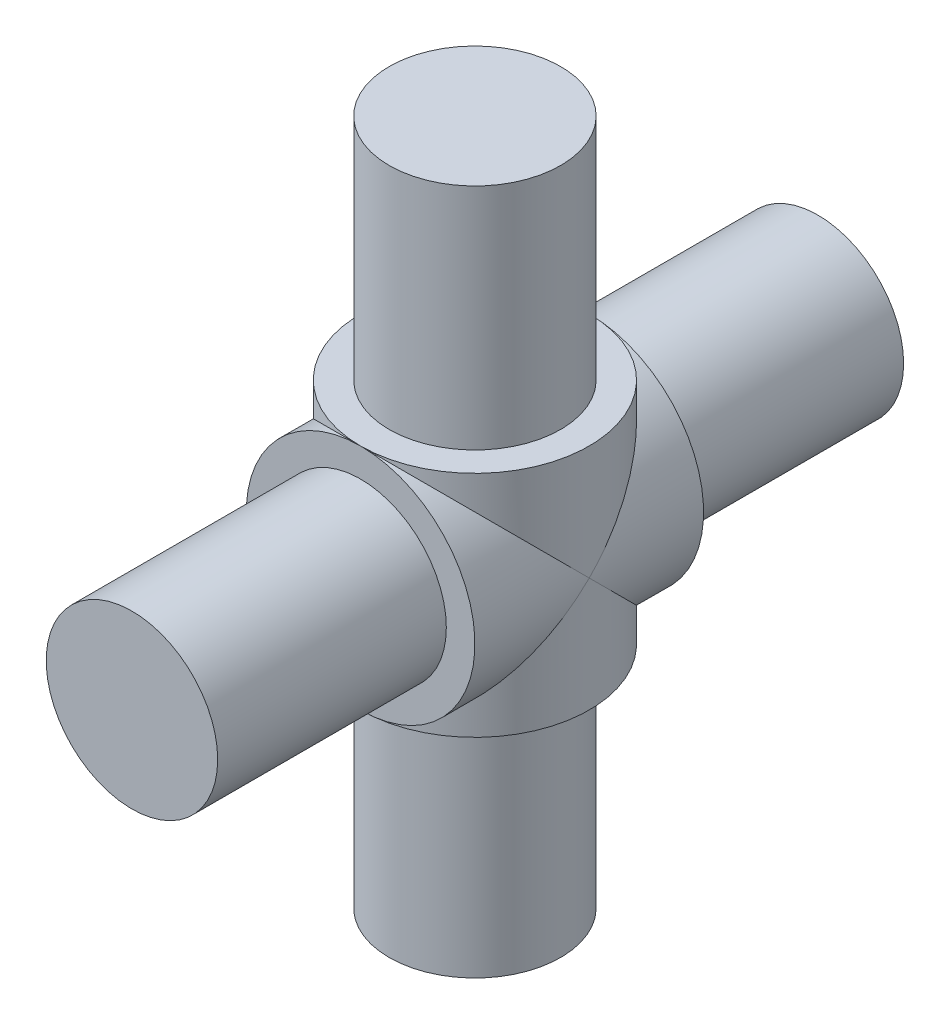
from build123d import *

# Parameters (mm, degrees)
SKETCH1_R           = 10
BOSS_EXTRUDE1_DEPTH = 10
SKETCH2_R           = 7.5
BOSS_EXTRUDE2_DEPTH = 30
SKETCH3_R           = 10
BOSS_EXTRUDE3_DEPTH = 10
SKETCH4_R           = 7.5
BOSS_EXTRUDE4_DEPTH = 30


with BuildPart() as part:
    # Sketch1 → Boss-Extrude1 (new body, symmetric)
    with BuildSketch(Plane.XY):
        Circle(SKETCH1_R)
    extrude(amount=BOSS_EXTRUDE1_DEPTH, both=True)

    # Sketch2 → Boss-Extrude2 (add, symmetric)
    with BuildSketch(Plane.XY):
        Circle(SKETCH2_R)
    extrude(amount=BOSS_EXTRUDE2_DEPTH, both=True)

    # Sketch3 → Boss-Extrude3 (add, symmetric)
    with BuildSketch(Plane(origin=(0, 0, 0), x_dir=(1, 0, 0), z_dir=(0, 1, 0))):
        Circle(SKETCH3_R)
    extrude(amount=BOSS_EXTRUDE3_DEPTH, both=True)

    # Sketch4 → Boss-Extrude4 (add, symmetric)
    with BuildSketch(Plane(origin=(0, 0, 0), x_dir=(1, 0, 0), z_dir=(0, 1, 0))):
        Circle(SKETCH4_R)
    extrude(amount=BOSS_EXTRUDE4_DEPTH, both=True)


solid = part.part
